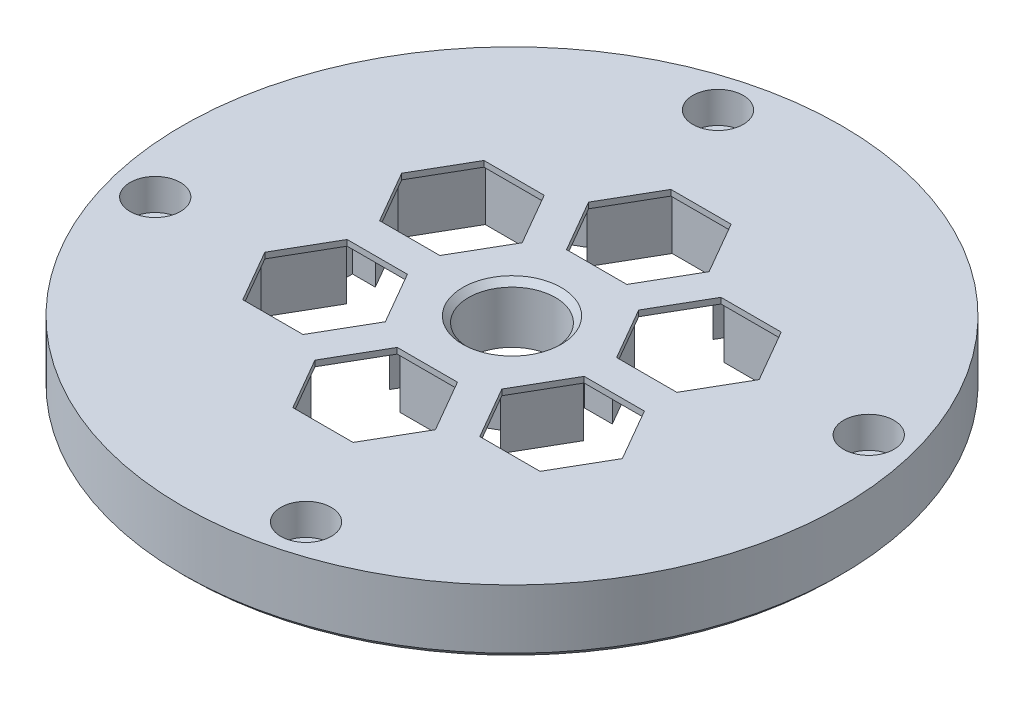
from build123d import *

# Parameters (mm, degrees)
SKETCH2_R           = 56.85
SKETCH2_R_2         = 44.5
BOSS_EXTRUDE1_DEPTH = 1.2
SKETCH3_R           = 56.85
BOSS_EXTRUDE2_DEPTH = 10
SKETCH4_R           = 2.65
CUT_EXTRUDE1_DEPTH  = 12.2
SKETCH5_R           = 7.5
CUT_EXTRUDE2_DEPTH  = 12.2
CUT_EXTRUDE4_DEPTH  = 11
SKETCH7_W           = 20
SKETCH7_H           = 5
BOSS_EXTRUDE3_DEPTH = 1
BOSS_EXTRUDE4_DEPTH = 1
CIRPATTERN1_COUNT   = 6
SKETCH9_R           = 4.35
CUT_EXTRUDE5_DEPTH  = 5.4
CHAMFER1_SIZE       = 1
CHAMFER2_SIZE       = 1


with BuildPart() as part:
    # Sketch2 → Boss-Extrude1 (new body)
    with BuildSketch(Plane(origin=(0, 0, 0), x_dir=(1, 0, 0), z_dir=(0, 1, 0))):
        Circle(SKETCH2_R)
        Circle(SKETCH2_R_2, mode=Mode.SUBTRACT)
    extrude(amount=BOSS_EXTRUDE1_DEPTH)

    # Sketch3 → Boss-Extrude2 (add)
    with BuildSketch(Plane(origin=(0, 1.2, 0), x_dir=(1, 0, 0), z_dir=(0, 1, 0))):
        Circle(SKETCH3_R)
    extrude(amount=BOSS_EXTRUDE2_DEPTH)

    # Sketch4 → Cut-Extrude1 (cut, through all)
    with BuildSketch(Plane(origin=(0, 11.2, 0), x_dir=(1, 0, 0), z_dir=(0, 1, 0))):
        with Locations((-13.005657016, 48.537772771)):
            Circle(SKETCH4_R)
        with Locations((48.537772771, 13.005657016)):
            Circle(SKETCH4_R)
        with Locations((13.005657016, -48.537772771)):
            Circle(SKETCH4_R)
        with Locations((-48.537772771, -13.005657016)):
            Circle(SKETCH4_R)
    extrude(amount=-CUT_EXTRUDE1_DEPTH, mode=Mode.SUBTRACT)

    # Sketch5 → Cut-Extrude2 (cut, through all)
    with BuildSketch(Plane(origin=(0, 11.2, 0), x_dir=(1, 0, 0), z_dir=(0, 1, 0))):
        Circle(SKETCH5_R)
    extrude(amount=-CUT_EXTRUDE2_DEPTH, mode=Mode.SUBTRACT)

    # Sketch6 → Cut-Extrude4 (cut, through all)
    with BuildSketch(Plane.XZ.offset(-1.2)):
        Polygon((12.845675931, 27.249363369), (10.876265015, 23.838243602), (5.505548638, 33.14059724), (-5.505548638, 33.14059724), (-10.876265015, 23.838243603), (-12.845675931, 27.249363369), (-17.175802949, 24.749363369), (-15.206392034, 21.338243603), (-25.947824787, 21.338243603), (-31.453373426, 11.802353637), (-26.082657049, 2.5), (-30.02147888, 2.5), (-30.02147888, -2.5), (-26.082657049, -2.5), (-31.453373426, -11.802353638), (-25.947824787, -21.338243603), (-15.206392034, -21.338243603), (-17.175802949, -24.749363369), (-12.845675931, -27.249363369), (-10.876265015, -23.838243603), (-5.505548638, -33.14059724), (5.505548638, -33.14059724), (10.876265015, -23.838243603), (12.845675931, -27.249363369), (17.175802949, -24.749363369), (15.206392034, -21.338243603), (25.947824787, -21.338243603), (31.453373426, -11.802353638), (26.082657049, -2.5), (30.02147888, -2.5), (30.02147888, 2.5), (26.082657049, 2.5), (31.453373426, 11.802353637), (25.947824787, 21.338243602), (15.206392034, 21.338243602), (17.175802949, 24.749363369), align=None)
        Polygon((-2.845675931, 9.928855294), (-5.235884115, 14.06881731), (5.235884115, 14.06881731), (2.845675931, 9.928855294), (7.175802949, 7.428855294), (9.566011134, 11.56881731), (14.801895249, 2.5), (10.02147888, 2.5), (10.02147888, -2.5), (14.801895249, -2.5), (9.566011134, -11.56881731), (7.175802949, -7.428855294), (2.845675931, -9.928855294), (5.235884115, -14.06881731), (-5.235884115, -14.06881731), (-2.845675931, -9.928855294), (-7.175802949, -7.428855294), (-9.566011134, -11.56881731), (-14.801895249, -2.5), (-10.02147888, -2.5), (-10.02147888, 2.5), (-14.801895249, 2.5), (-9.566011134, 11.56881731), (-7.175802949, 7.428855294), align=None, mode=Mode.SUBTRACT)
    extrude(amount=-CUT_EXTRUDE4_DEPTH, mode=Mode.SUBTRACT)

    # Sketch7 → Boss-Extrude3 (add)
    with BuildSketch(Plane(origin=(0, 11.2, 0), x_dir=(1, 0, 0), z_dir=(0, 1, 0))):
        Polygon((-17.175802949, 24.749363369), (-7.175802949, 7.428855294), (-2.845675931, 9.928855294), (-12.845675931, 27.249363369), align=None)
        Polygon((17.175802949, 24.749363369), (12.845675931, 27.249363369), (2.845675931, 9.928855294), (7.175802949, 7.428855294), align=None)
        with Locations((20.02147888, 0)):
            Rectangle(SKETCH7_W, SKETCH7_H)
        Polygon((12.845675931, -27.249363369), (17.175802949, -24.749363369), (7.175802949, -7.428855294), (2.845675931, -9.928855294), align=None)
        Polygon((-17.175802949, -24.749363369), (-12.845675931, -27.249363369), (-2.845675931, -9.928855294), (-7.175802949, -7.428855294), align=None)
        with Locations((-20.02147888, 0)):
            Rectangle(SKETCH7_W, SKETCH7_H)
    extrude(amount=-BOSS_EXTRUDE3_DEPTH)

    # Sketch8 → Boss-Extrude4 (add)
    with BuildSketch(Plane(origin=(0, 11.2, 0), x_dir=(1, 0, 0), z_dir=(0, 1, 0))):
        Polygon((5.542562584, -14.00470728), (-5.542562584, -14.00470728), (-11.085125168, -23.60470728), (-5.542562584, -33.20470728), (5.542562584, -33.20470728), (11.085125168, -23.60470728), align=None)
        Polygon((5.196152423, -14.60470728), (-5.196152423, -14.60470728), (-10.392304845, -23.60470728), (-5.196152423, -32.60470728), (5.196152423, -32.60470728), (10.392304845, -23.60470728), align=None, mode=Mode.SUBTRACT)
    boss_extrude4 = extrude(amount=-BOSS_EXTRUDE4_DEPTH)

    # CirPattern1: Boss-Extrude4 ×6 about axis
    cirpattern1_axis = Axis((0, 0, 0), (0, 1, 0))
    for i in range(1, CIRPATTERN1_COUNT):
        add(boss_extrude4.rotate(cirpattern1_axis, i * 360 / CIRPATTERN1_COUNT))

    # Sketch9 → Cut-Extrude5 (cut)
    with BuildSketch(Plane(origin=(0, 11.2, 0), x_dir=(1, 0, 0), z_dir=(0, 1, 0))):
        with Locations((-13.005657016, 48.537772771)):
            Circle(SKETCH9_R)
        with Locations((48.537772771, 13.005657016)):
            Circle(SKETCH9_R)
        with Locations((13.005657016, -48.537772771)):
            Circle(SKETCH9_R)
        with Locations((-48.537772771, -13.005657016)):
            Circle(SKETCH9_R)
    extrude(amount=-CUT_EXTRUDE5_DEPTH, mode=Mode.SUBTRACT)

    # Chamfer1
    chamfer1_edges = [part.edges().sort_by_distance(p)[0] for p in [
        (-44.5, 0, 0),
        (-56.85, 0, 0),
    ]]
    chamfer(chamfer1_edges, length=CHAMFER1_SIZE)

    # Chamfer2
    chamfer2_edges = [part.edges().sort_by_distance(p)[0] for p in [
        (-7.5, 11.2, 0),
    ]]
    chamfer(chamfer2_edges, length=CHAMFER2_SIZE)


solid = part.part
